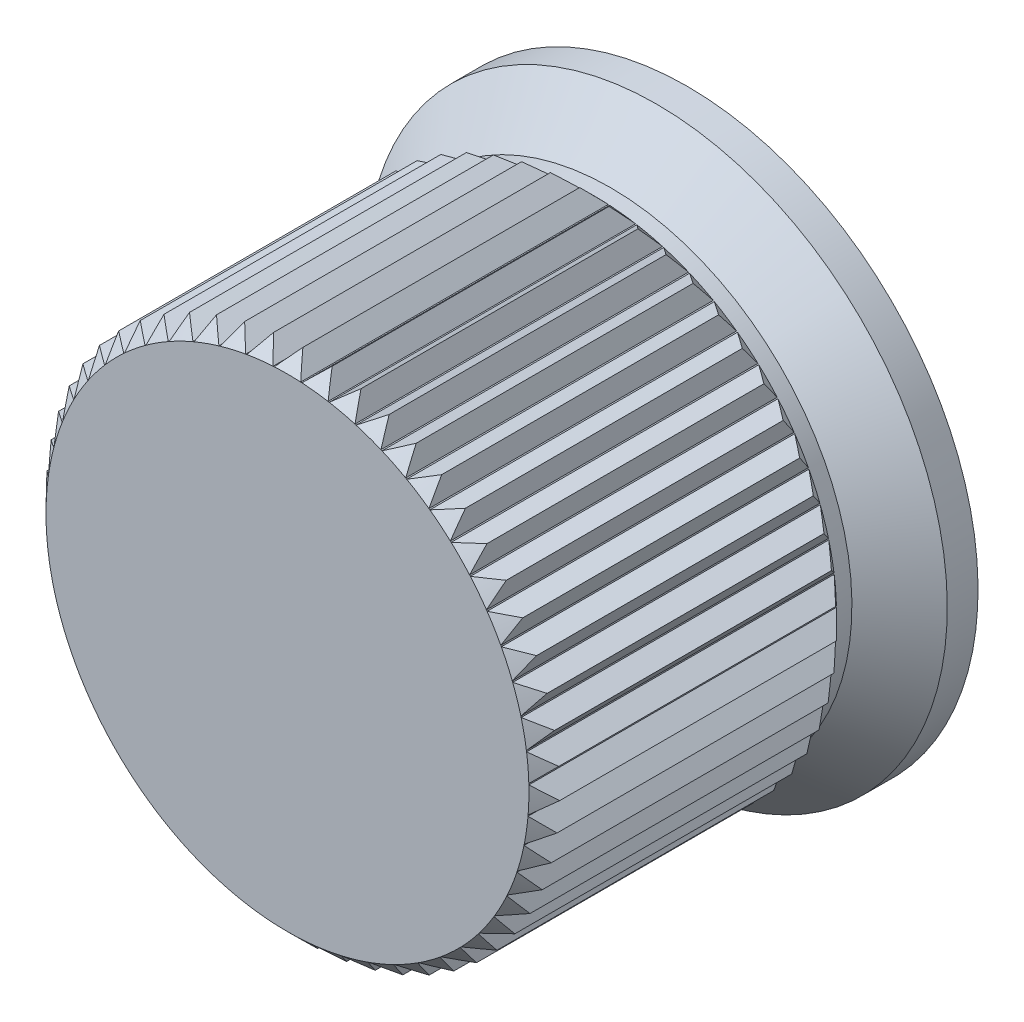
from build123d import *

# Parameters (mm, degrees)
BOSS_EXTRUDE1_DEPTH = 10
CIRPATTERN1_COUNT   = 55
SKETCH4_R           = 3
CUT_EXTRUDE1_DEPTH  = 8


with BuildPart() as part:
    # Sketch1 → Revolve1 (revolve)
    with BuildSketch(Plane(origin=(0, 0, 0), x_dir=(0, 0, -1), z_dir=(1, 0, 0))):
        Polygon((-10.5, 0), (-10.5, 7.85), (0, 7.85), (1.5, 9.45), (2.5, 9.45), (2.5, 7), (0, 7), (0, 0), align=None)
    revolve(axis=Axis((0, 0, 0), (0, 0, 1)))

    # Sketch2 → Boss-Extrude1 (add)
    with BuildSketch(Plane.XY.offset(10.5)):
        Polygon((0, 8.35), (0.429412342, 7.838246299), (-0.429412342, 7.838246299), align=None)
    boss_extrude1 = extrude(amount=-BOSS_EXTRUDE1_DEPTH)

    # CirPattern1: Boss-Extrude1 ×55 about axis
    cirpattern1_axis = Axis((0, 0, 0), (0, 0, 1))
    for i in range(1, CIRPATTERN1_COUNT):
        add(boss_extrude1.rotate(cirpattern1_axis, i * 360 / CIRPATTERN1_COUNT))

    # Sketch3 → Cut-Revolve1 (revolve, cut)
    with BuildSketch(Plane(origin=(0, 0, 0), x_dir=(0, 0, -1), z_dir=(1, 0, 0))):
        Polygon((-10.5, 7.85), (-10, 8.35), (-10.5, 8.35), align=None)
        Polygon((-1, 8.35), (-0.5, 8.35), (-0.5, 7.85), align=None)
    revolve(axis=Axis((0, 0, 0), (0, 0, 1)), mode=Mode.SUBTRACT)

    # Sketch4 → Cut-Extrude1 (cut)
    with BuildSketch(Plane(origin=(0, 0, 0), x_dir=(-1, 0, 0), z_dir=(0, 0, -1))):
        Circle(SKETCH4_R)
    extrude(amount=-CUT_EXTRUDE1_DEPTH, mode=Mode.SUBTRACT)


solid = part.part
